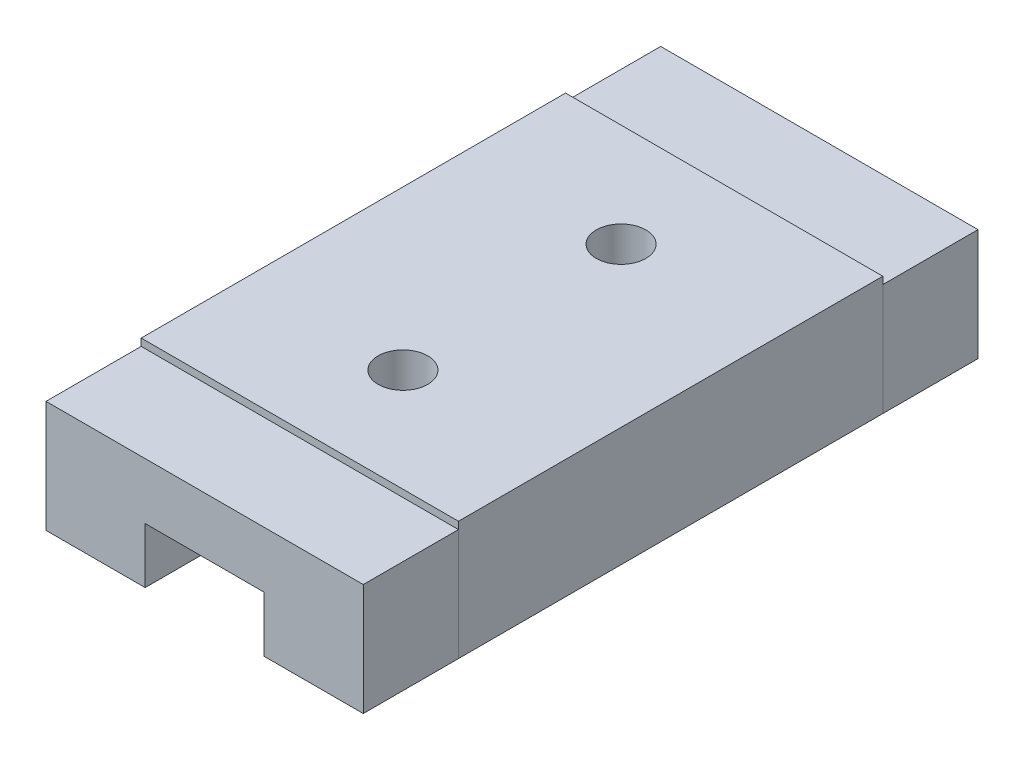
from build123d import *

# Parameters (mm, degrees)
BOSS_EXTRUDE1_DEPTH          = 10.7
M1_6X0_35_TAPPED_HOLE1_D     = 1.25
M1_6X0_35_TAPPED_HOLE1_DEPTH = 3.2
M1_6X0_35_TAPPED_HOLE1_TIP   = 0.375537887
BOSS_EXTRUDE2_DEPTH          = 2.4
BOSS_EXTRUDE3_DEPTH          = 2.4


with BuildPart() as part:
    # Sketch1 → Boss-Extrude1 (new body)
    with BuildSketch(Plane.XY):
        Polygon((-1.5, -1.5), (-1.5, -0.1), (1.5, -0.1), (1.5, -1.5), (4, -1.5), (4, 1.5), (-4, 1.5), (-4, -1.5), align=None)
    extrude(amount=BOSS_EXTRUDE1_DEPTH)

    # M1.6x0.35 Tapped Hole1
    with Locations(Plane(origin=(0, 1.5, 0), x_dir=(1, 0, 0), z_dir=(0, 1, 0))):
        with Locations((0, -2.6), (0, -8.1)):
            Hole(M1_6X0_35_TAPPED_HOLE1_D / 2, depth=M1_6X0_35_TAPPED_HOLE1_DEPTH)
            with Locations((0, 0, -(M1_6X0_35_TAPPED_HOLE1_DEPTH + M1_6X0_35_TAPPED_HOLE1_TIP / 2))):  # 118° drill point
                Cone(0, M1_6X0_35_TAPPED_HOLE1_D / 2, M1_6X0_35_TAPPED_HOLE1_TIP, mode=Mode.SUBTRACT)


with BuildPart() as body_2:
    # Sketch4 → Boss-Extrude2 (new body)
    with BuildSketch(Plane(origin=(0, 0, 0), x_dir=(-1, 0, 0), z_dir=(0, 0, -1))):
        Polygon((-4, 1.317876406), (4, 1.317876406), (4, -1.5), (1.5, -1.5), (1.5, -0.1), (-1.5, -0.1), (-1.5, -1.5), (-4, -1.5), align=None)
    extrude(amount=BOSS_EXTRUDE2_DEPTH)


with BuildPart() as body_3:
    # Sketch5 → Boss-Extrude3 (new body)
    with BuildSketch(Plane.XY.offset(10.7)):
        Polygon((-4, 1.317876406), (4, 1.317876406), (4, -1.5), (1.5, -1.5), (1.5, -0.1), (-1.5, -0.1), (-1.5, -1.5), (-4, -1.5), align=None)
    extrude(amount=BOSS_EXTRUDE3_DEPTH)


solid = Compound([part.part, body_2.part, body_3.part])
